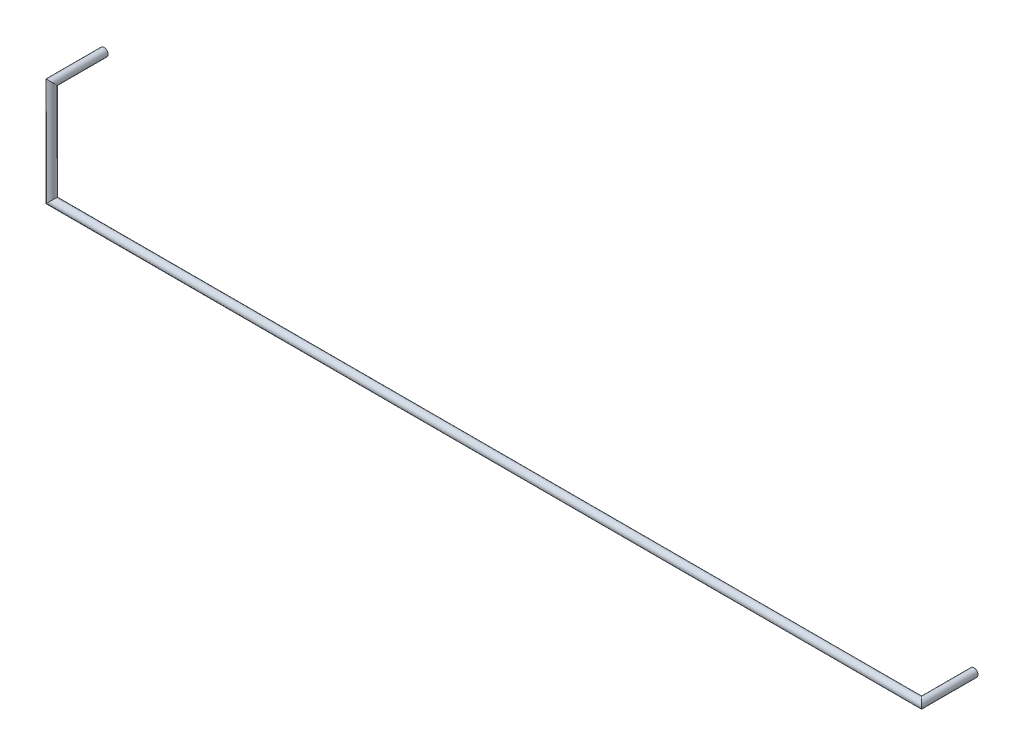
from build123d import *

# Parameters (mm, degrees)
SWEEP1_PROFILE_R = 0.2


with BuildPart() as part:
    # Sweep1: sweep along a curve in space
    with BuildLine() as sweep1_path:
        Line((0, 0, 0), (0, 0, 2.6))
        Line((0, 0, 2.6), (0, -5.08, 2.6))
        Line((0, -5.08, 2.6), (43.18, -5.08, 2.6))
        Line((43.18, -5.08, 2.6), (43.18, -5.08, 0))
    # Sweep1 profile (on start of the path) → Sweep1 (sweep)
    with BuildSketch(Plane.XY):
        Circle(SWEEP1_PROFILE_R)
    sweep(path=sweep1_path.line, transition=Transition.RIGHT)


solid = part.part
